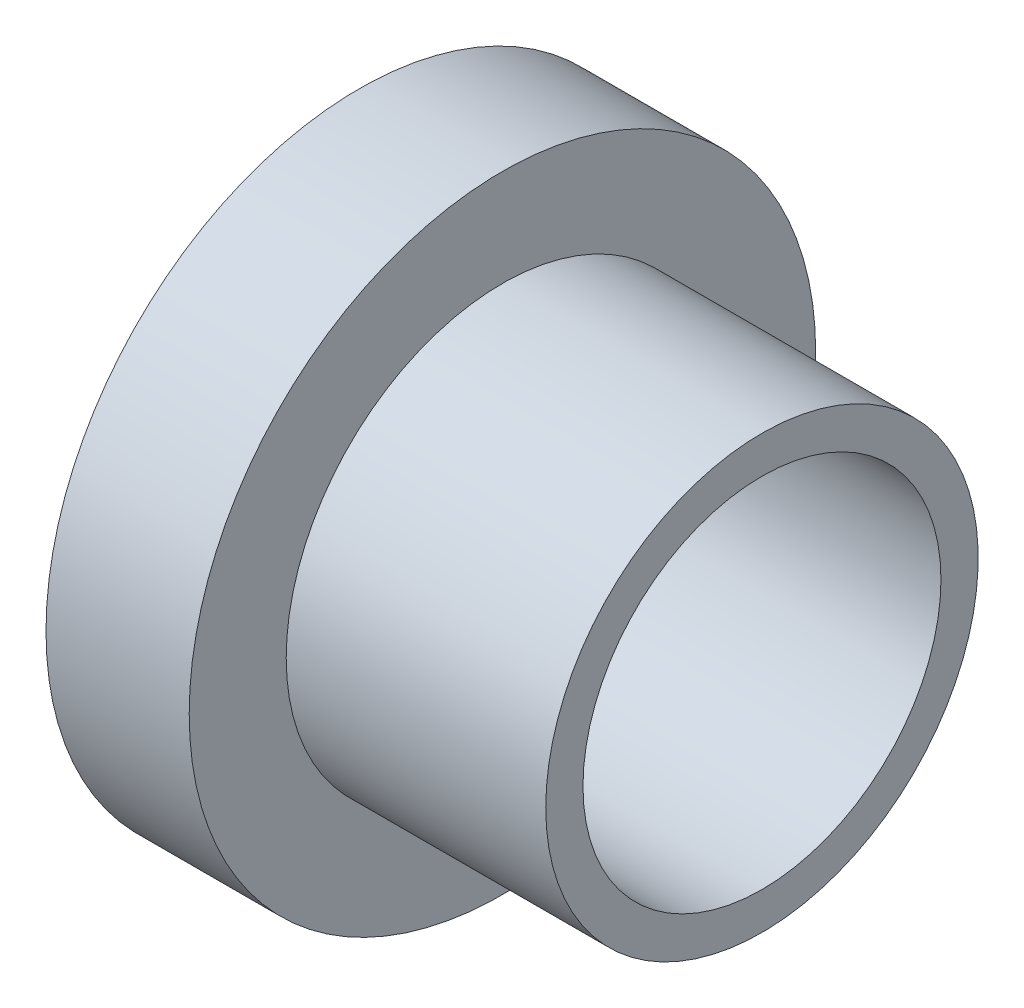
from build123d import *


with BuildPart() as part:
    # Esquisse1 → Révolution1 (revolve)
    with BuildSketch(Plane.XY, mode=Mode.PRIVATE) as r_volution1_sk:
        Polygon((0, 0), (0, 3.75), (4, 3.75), (4, 1.04), (11.25, 1.04), (11.25, 0), align=None)
    revolve(r_volution1_sk.sketch.rotate(Axis((0, -5, 0), (1, 0, 0)), 90), axis=Axis((0, -5, 0), (1, 0, 0)))  # turned: the seam where the file's is


solid = part.part
